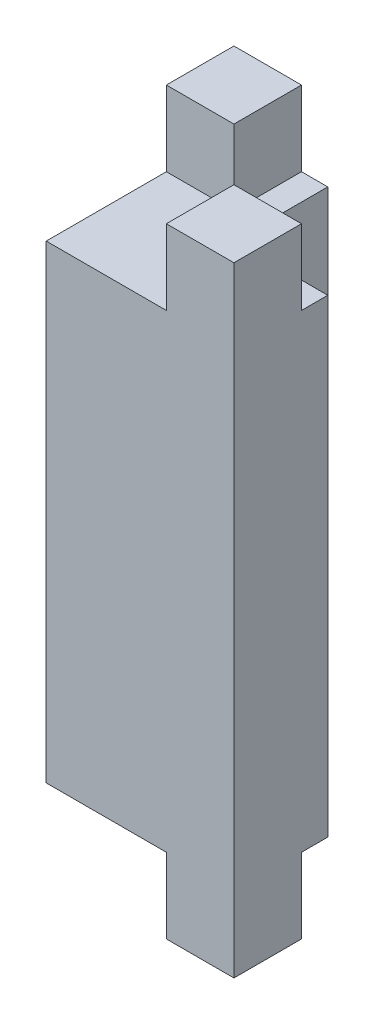
from build123d import *

# Parameters (mm, degrees)
BOSS_EXTRUDE2_DEPTH = 25
SKETCH13_W          = 3.6
SKETCH13_H          = 3.6
BOSS_EXTRUDE3_DEPTH = 4
SKETCH15_W          = 3.6
SKETCH15_H          = 3.6
BOSS_EXTRUDE4_DEPTH = 4


with BuildPart() as part:
    # Sketch12 → Boss-Extrude2 (new body)
    with BuildSketch(Plane(origin=(0, 0, 0), x_dir=(1, 0, 0), z_dir=(0, 1, 0))):
        Polygon((-5, -5), (5, -5), (5, 0), (0, 0), (0, 5), (-5, 5), (-5, 0), align=None)
    extrude(amount=BOSS_EXTRUDE2_DEPTH)

    # Sketch13 → Boss-Extrude3 (add)
    with BuildSketch(Plane(origin=(0, 0, 0), x_dir=(1, 0, 0), z_dir=(0, 1, 0))):
        with Locations((-3.2, 3.2)):
            Rectangle(SKETCH13_W, SKETCH13_H)
        with Locations((3.2, -3.2)):
            Rectangle(SKETCH13_W, SKETCH13_H)
    extrude(amount=-BOSS_EXTRUDE3_DEPTH)

    # Sketch15 → Boss-Extrude4 (add)
    with BuildSketch(Plane(origin=(0, 25, 0), x_dir=(1, 0, 0), z_dir=(0, 1, 0))):
        with Locations((-3.2, 3.2)):
            Rectangle(SKETCH15_W, SKETCH15_H)
        with Locations((3.2, -3.2)):
            Rectangle(SKETCH15_W, SKETCH15_H)
    extrude(amount=BOSS_EXTRUDE4_DEPTH)


solid = part.part
